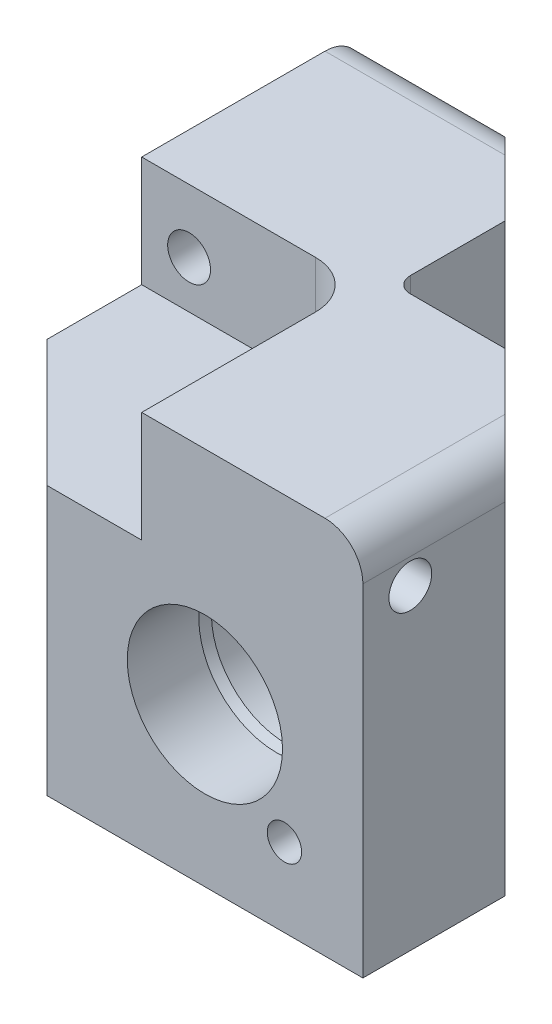
from build123d import *

# Parameters (mm, degrees)
BOSS_EXTRUDE2_DEPTH          = 38.1
FILLET3_R                    = 0.127
FILLET16_R                   = 3.81
CUT_EXTRUDE3_DEPTH           = 11.1125
F_18_0_1695_DIAMETER_HOLE1_D = 4.3053
SKETCH101_R                  = 2.54
CUT_EXTRUDE4_DEPTH           = 17.78
SKETCH102_W                  = 10.16
SKETCH102_H                  = 1.27
CHAMFER1_SIZE                = 12.7
FILLET17_R                   = 1.5875


with BuildPart() as part:
    # Sketch7 → Boss-Extrude2 (new body)
    with BuildSketch(Plane(origin=(0, 0, 0), x_dir=(1, 0, 0), z_dir=(0, 1, 0))):
        Polygon((0, 0), (11.1125, 0), (20.6375, -9.525), (20.6375, -23.8125), (-23.8125, -23.8125), align=None)
    boss_extrude2 = extrude(amount=BOSS_EXTRUDE2_DEPTH)

    # Sketch24 → Port Manifold (revolve, cut)
    with BuildSketch(Plane.ZY.offset(-4.7625)):
        with BuildLine():
            Line((23.8125, 15.875), (23.8125, 23.6728))
            Line((23.8125, 23.6728), (16.6243, 23.6728))
            Line((16.6243, 23.6728), (15.62896205, 23.4061))
            Line((15.62896205, 23.4061), (9.8679, 23.4061))
            ThreePointArc((9.8679, 23.4061), (9.724215902, 23.346584098), (9.6647, 23.2029))
            Line((9.6647, 23.2029), (9.6647, 19.7485))
            Line((9.6647, 19.7485), (9.224759095, 19.4945))
            Line((9.224759095, 19.4945), (6.3627, 19.4945))
            ThreePointArc((6.3627, 19.4945), (6.219015902, 19.434984098), (6.1595, 19.2913))
            Line((6.1595, 19.2913), (6.1595, 16.37500027))
            Line((6.1595, 16.37500027), (4.703034592, 16.52397))
            Line((4.703034592, 16.52397), (1.4605, 17.392804525))
            Line((1.4605, 17.392804525), (1.4605, 15.875))
            Line((1.4605, 15.875), (23.8125, 15.875))
        make_face()
    port_manifold = revolve(axis=Axis((4.7625, 15.875, 1.4605), (0, 0, 1)), mode=Mode.SUBTRACT)

    # Fillet3
    fillet3_edges = [part.edges().sort_by_distance(p)[0] for p in [
        (4.7625, 15.37499973, 6.1595),
    ]]
    fillet(fillet3_edges, radius=FILLET3_R)

    # Sketch27 → #8-32 Tapped Hole1 (revolve, cut)
    with BuildSketch(Plane(origin=(12.754927948, 7.882572052, 23.8125), x_dir=(0, -1, 0), z_dir=(1, 0, 0))):
        Polygon((0, 0), (0, 11.197806461), (1.7272, 10.16), (1.7272, 0), align=None)
    f_8_32_tapped_hole1 = revolve(axis=Axis((12.754927948, 7.882572052, 30.1625), (0, 0, -1)), mode=Mode.SUBTRACT)

    # Sketch90 → 9/64 (0.14063) Diameter Hole1 (revolve, cut)
    with BuildSketch(Plane(origin=(4.7625, 15.875, 0), x_dir=(0, 1, 0), z_dir=(1, 0, 0))):
        Polygon((0, 0), (0, 3.81), (1.786001, 2.736862334), (1.786001, 0), align=None)
    f_9_64_0_14063_diameter_hole1 = revolve(axis=Axis((4.7625, 15.875, -6.35), (0, 0, 1)), mode=Mode.SUBTRACT)

    # Mirror6: Boss-Extrude2, Port Manifold, #8-32 Tapped Hole1, 9/64 (0.14063) Diameter Hole1 across Plane1
    add(boss_extrude2.mirror(Plane(origin=(0, 0, 0), x_dir=(0.707106781, 0, -0.707106781), z_dir=(0.707106781, 0, 0.707106781))))
    add(port_manifold.mirror(Plane(origin=(0, 0, 0), x_dir=(0.707106781, 0, -0.707106781), z_dir=(0.707106781, 0, 0.707106781))), mode=Mode.SUBTRACT)
    add(f_8_32_tapped_hole1.mirror(Plane(origin=(0, 0, 0), x_dir=(0.707106781, 0, -0.707106781), z_dir=(0.707106781, 0, 0.707106781))), mode=Mode.SUBTRACT)
    add(f_9_64_0_14063_diameter_hole1.mirror(Plane(origin=(0, 0, 0), x_dir=(0.707106781, 0, -0.707106781), z_dir=(0.707106781, 0, 0.707106781))), mode=Mode.SUBTRACT)

    # Fillet16
    fillet16_edges = [part.edges().sort_by_distance(p)[0] for p in [
        (20.6375, 38.1, 16.66875),
        (-16.66875, 38.1, -20.6375),
    ]]
    fillet(fillet16_edges, radius=FILLET16_R)

    # Sketch93 → Cut-Extrude3 (cut)
    with BuildSketch(Plane(origin=(0, 38.1, 0), x_dir=(1, 0, 0), z_dir=(0, 1, 0))):
        with BuildLine():
            Line((-23.8125, -23.8125), (-1.5875, -23.8125))
            Line((-1.5875, -23.8125), (-1.5875, -6.35))
            ThreePointArc((-1.5875, -6.35), (-2.982403955, -2.982403955), (-6.35, -1.5875))
            Line((-6.35, -1.5875), (-23.8125, -1.5875))
            Line((-23.8125, -1.5875), (-23.8125, -23.8125))
        make_face()
    extrude(amount=-CUT_EXTRUDE3_DEPTH, mode=Mode.SUBTRACT)

    # #18 (0.1695) Diameter Hole1 (through all)
    with Locations(Plane.ZY.offset(1.5875)):
        with Locations((19.05, 31.75)):
            f_18_0_1695_diameter_hole1 = Hole(F_18_0_1695_DIAMETER_HOLE1_D / 2)

    # Mirror9: #18 (0.1695) Diameter Hole1 across plane
    add(f_18_0_1695_diameter_hole1.mirror(Plane(origin=(0, 0, 0), x_dir=(-0.707106781, 0, 0.707106781), z_dir=(0.707106781, 0, 0.707106781))), mode=Mode.SUBTRACT)

    # Sketch101 → Cut-Extrude4 (cut)
    with BuildSketch(Plane.XZ):
        with Locations((-9.8425, 9.8425)):
            Circle(SKETCH101_R)
    extrude(amount=-CUT_EXTRUDE4_DEPTH, mode=Mode.SUBTRACT)

    # Sketch102 → Cut-Revolve1 (revolve, cut)
    with BuildSketch(Plane(origin=(0, 15.875, 0), x_dir=(1, 0, 0), z_dir=(0, 1, 0))):
        with Locations((-5.5245, -9.9695)):
            Rectangle(SKETCH102_W, SKETCH102_H)
    cut_revolve1 = revolve(axis=Axis((-0.4445, 15.875, 9.3345), (-1, 0, 0)), mode=Mode.SUBTRACT)

    # Mirror10: Cut-Revolve1 across plane
    add(cut_revolve1.mirror(Plane(origin=(0, 0, 0), x_dir=(-0.707106781, 0, 0.707106781), z_dir=(0.707106781, 0, 0.707106781))), mode=Mode.SUBTRACT)

    # Chamfer1
    chamfer1_edges = [part.edges().sort_by_distance(p)[0] for p in [
        (-23.8125, 13.49375, 23.8125),
    ]]
    chamfer(chamfer1_edges, length=CHAMFER1_SIZE)

    # Fillet17
    fillet17_edges = [part.edges().sort_by_distance(p)[0] for p in [
        (0, 19.05, 0),
    ]]
    fillet(fillet17_edges, radius=FILLET17_R)

    # Sketch104 → 1/8 NPT Tapped Hole1 (revolve, cut)
    with BuildSketch(Plane(origin=(-9.8425, 0, 9.8425), x_dir=(0, 0, -1), z_dir=(1, 0, 0))):
        Polygon((0, 0), (0, 11.684), (4.2164, 9.150531286), (4.2164, 6.858), (4.537401096, 6.858), (4.7427388, 0), align=None)
    revolve(axis=Axis((-9.8425, -6.35, 9.8425), (0, 1, 0)), mode=Mode.SUBTRACT)


solid = part.part
